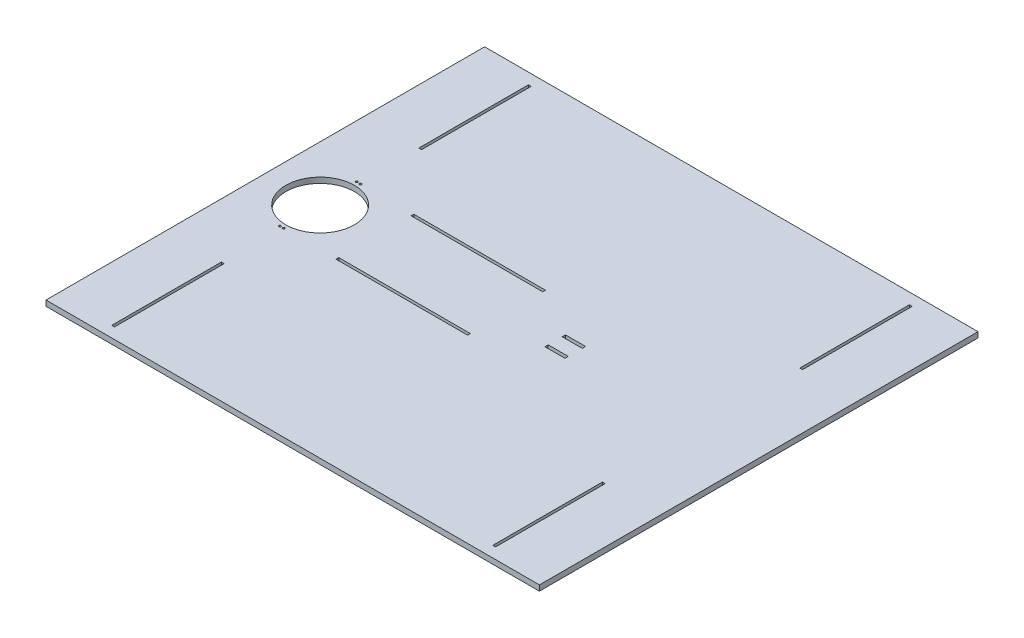
from build123d import *

# Parameters (mm, degrees)
SKETCH1_W           = 900
SKETCH1_H           = 800
SKETCH1_W_2         = 5
SKETCH1_H_2         = 200
BOSS_EXTRUDE1_DEPTH = 10
SKETCH2_R           = 62.5
CUT_EXTRUDE4_DEPTH  = 196
SKETCH3_R           = 2
SKETCH3_W           = 36.55
SKETCH3_H           = 6
SKETCH3_W_2         = 240
SKETCH3_H_2         = 5
CUT_EXTRUDE5_DEPTH  = 11


with BuildPart() as part:
    # Sketch1 → Boss-Extrude1 (new body)
    with BuildSketch(Plane(origin=(0, 0, 0), x_dir=(1, 0, 0), z_dir=(0, 1, 0))):
        with Locations((50, -100)):
            Rectangle(SKETCH1_W, SKETCH1_H)
        with Locations((397.5, 180)):
            Rectangle(SKETCH1_W_2, SKETCH1_H_2, mode=Mode.SUBTRACT)
        with Locations((-297.5, 180)):
            Rectangle(SKETCH1_W_2, SKETCH1_H_2, mode=Mode.SUBTRACT)
        with Locations((-297.5, -380)):
            Rectangle(SKETCH1_W_2, SKETCH1_H_2, mode=Mode.SUBTRACT)
        with Locations((397.5, -380)):
            Rectangle(SKETCH1_W_2, SKETCH1_H_2, mode=Mode.SUBTRACT)
    extrude(amount=BOSS_EXTRUDE1_DEPTH)

    # Sketch2 → Cut-Extrude4 (cut)
    with BuildSketch(Plane(origin=(0, 0, 0), x_dir=(1, 0, 0), z_dir=(0, 1, 0))):
        with Locations((-300, -100)):
            Circle(SKETCH2_R)
    extrude(amount=CUT_EXTRUDE4_DEPTH, mode=Mode.SUBTRACT)

    # Sketch3 → Cut-Extrude5 (cut, through all)
    with BuildSketch(Plane(origin=(0, 0, 0), x_dir=(1, 0, 0), z_dir=(0, 1, 0))):
        with Locations((-296.5, -30)):
            Circle(SKETCH3_R)
        with Locations((-303.5, -30)):
            Circle(SKETCH3_R)
        with Locations((-303.5, -170)):
            Circle(SKETCH3_R)
        with Locations((-296.5, -170)):
            Circle(SKETCH3_R)
        with Locations((147.13212951, -115.75)):
            Rectangle(SKETCH3_W, SKETCH3_H)
        with Locations((147.13212951, -84.25)):
            Rectangle(SKETCH3_W, SKETCH3_H)
        with Locations((-80, -168.5)):
            Rectangle(SKETCH3_W_2, SKETCH3_H_2)
        with Locations((-80, -31.5)):
            Rectangle(SKETCH3_W_2, SKETCH3_H_2)
    extrude(amount=CUT_EXTRUDE5_DEPTH, mode=Mode.SUBTRACT)


solid = part.part
